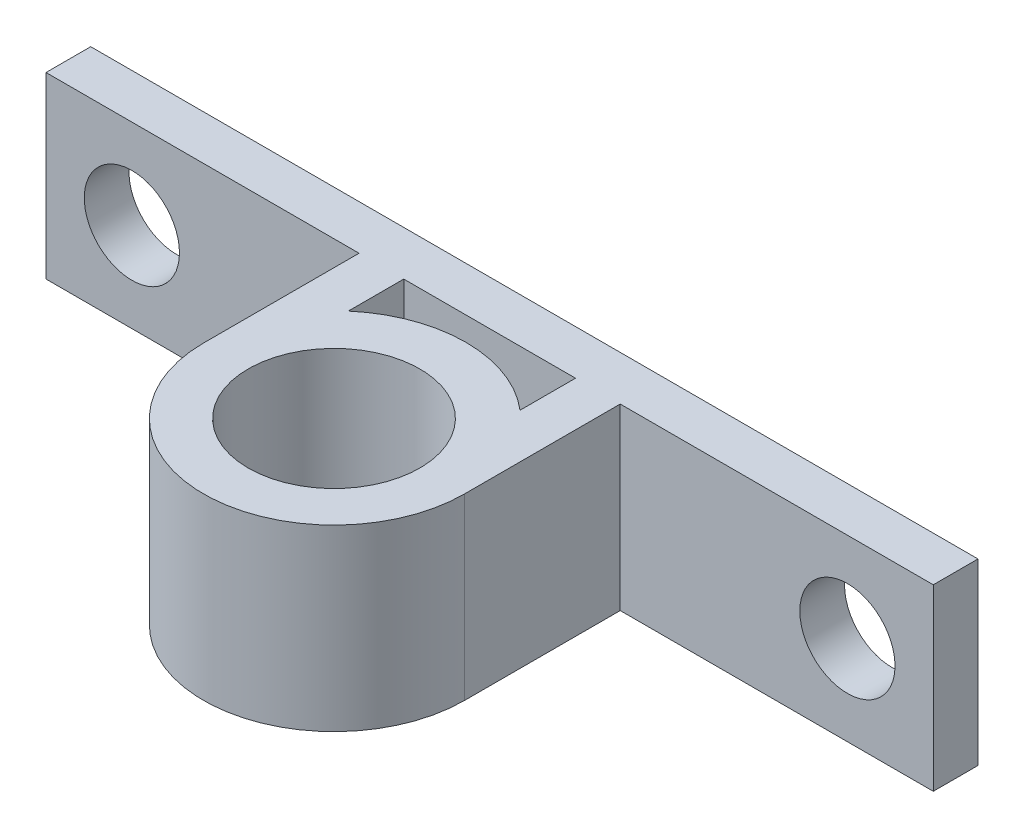
from build123d import *

# Parameters (mm, degrees)
SKETCH1_R           = 6.096
BOSS_EXTRUDE1_DEPTH = 12.7
SKETCH2_R           = 3.3782
CUT_EXTRUDE1_DEPTH  = 4.175


with BuildPart() as part:
    # Sketch1 → Boss-Extrude1 (new body)
    with BuildSketch(Plane(origin=(0, 0, 0), x_dir=(1, 0, 0), z_dir=(0, 1, 0))):
        with BuildLine():
            Line((-9.271, 0), (-9.271, 11.049))
            Line((-9.271, 11.049), (-31.496, 11.049))
            Line((-31.496, 11.049), (-31.496, 14.224))
            Line((-31.496, 14.224), (-6.096, 14.224))
            Line((-6.096, 14.224), (6.096, 14.224))
            Line((6.096, 14.224), (31.496, 14.224))
            Line((31.496, 14.224), (31.496, 11.049))
            Line((31.496, 11.049), (9.271, 11.049))
            Line((9.271, 11.049), (9.271, 0))
            ThreePointArc((9.271, 0), (0, -9.271), (-9.271, 0))
        make_face()
        Circle(SKETCH1_R, mode=Mode.SUBTRACT)
        with BuildLine():
            Line((-6.096, 7.112), (-6.096, 11.049))
            Line((-6.096, 11.049), (6.096, 11.049))
            Line((6.096, 11.049), (6.096, 7.112))
            ThreePointArc((6.096, 7.112), (0, 9.367057169), (-6.096, 7.112))
        make_face(mode=Mode.SUBTRACT)
    extrude(amount=BOSS_EXTRUDE1_DEPTH)

    # Sketch2 → Cut-Extrude1 (cut, through all)
    with BuildSketch(Plane.XY.offset(-11.049)):
        with Locations((-25.4, 6.35)):
            Circle(SKETCH2_R)
        with Locations((25.4, 6.35)):
            Circle(SKETCH2_R)
    extrude(amount=-CUT_EXTRUDE1_DEPTH, mode=Mode.SUBTRACT)


solid = part.part
